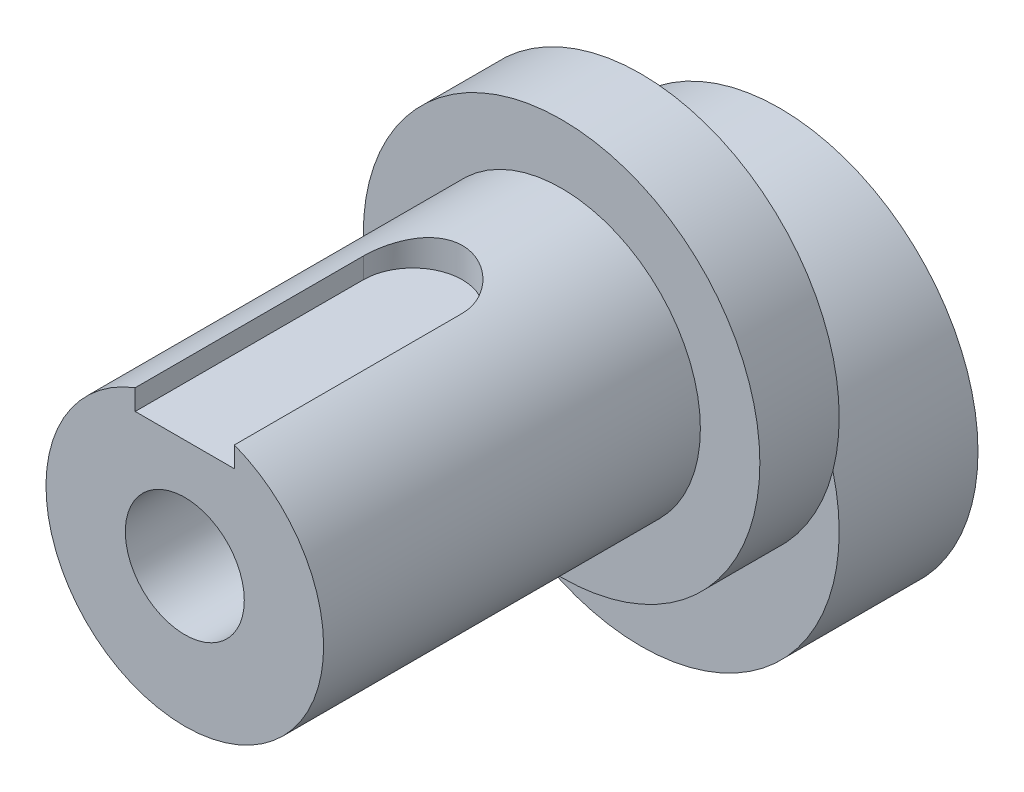
from build123d import *

# Parameters (mm, degrees)
SKETCH1_R           = 10
SKETCH1_R_2         = 3
BOSS_EXTRUDE1_DEPTH = 7
SKETCH2_R           = 10
SKETCH2_R_2         = 3
BOSS_EXTRUDE2_DEPTH = 4
SKETCH3_R           = 7
SKETCH3_R_2         = 3
BOSS_EXTRUDE3_DEPTH = 19
CUT_EXTRUDE1_START  = 20.5
CUT_EXTRUDE1_DEPTH  = 10


with BuildPart() as part:
    # Sketch1 → Boss-Extrude1 (new body)
    with BuildSketch(Plane.XY):
        Circle(SKETCH1_R)
        with Locations((0, 5)):
            Circle(SKETCH1_R_2, mode=Mode.SUBTRACT)
    extrude(amount=BOSS_EXTRUDE1_DEPTH)

    # Sketch2 → Boss-Extrude2 (add)
    with BuildSketch(Plane.XY.offset(7)):
        with Locations((0, 5)):
            Circle(SKETCH2_R)
        with Locations((0, 5)):
            Circle(SKETCH2_R_2, mode=Mode.SUBTRACT)
    extrude(amount=BOSS_EXTRUDE2_DEPTH)

    # Sketch3 → Boss-Extrude3 (add)
    with BuildSketch(Plane.XY.offset(11)):
        with Locations((0, 5)):
            Circle(SKETCH3_R)
        with Locations((0, 5)):
            Circle(SKETCH3_R_2, mode=Mode.SUBTRACT)
    extrude(amount=BOSS_EXTRUDE3_DEPTH)

    # Sketch5 → Cut-Extrude1 (cut)
    with BuildSketch(Plane(origin=(0, 0, 0), x_dir=(1, 0, 0), z_dir=(0, 1, 0)).offset(CUT_EXTRUDE1_START)):
        with BuildLine():
            Line((2.5, -44), (-2.5, -44))
            Line((-2.5, -44), (-2.5, -18.5))
            ThreePointArc((-2.5, -18.5), (0, -16), (2.5, -18.5))
            Line((2.5, -18.5), (2.5, -44))
        make_face()
    extrude(amount=-CUT_EXTRUDE1_DEPTH, mode=Mode.SUBTRACT)


solid = part.part
